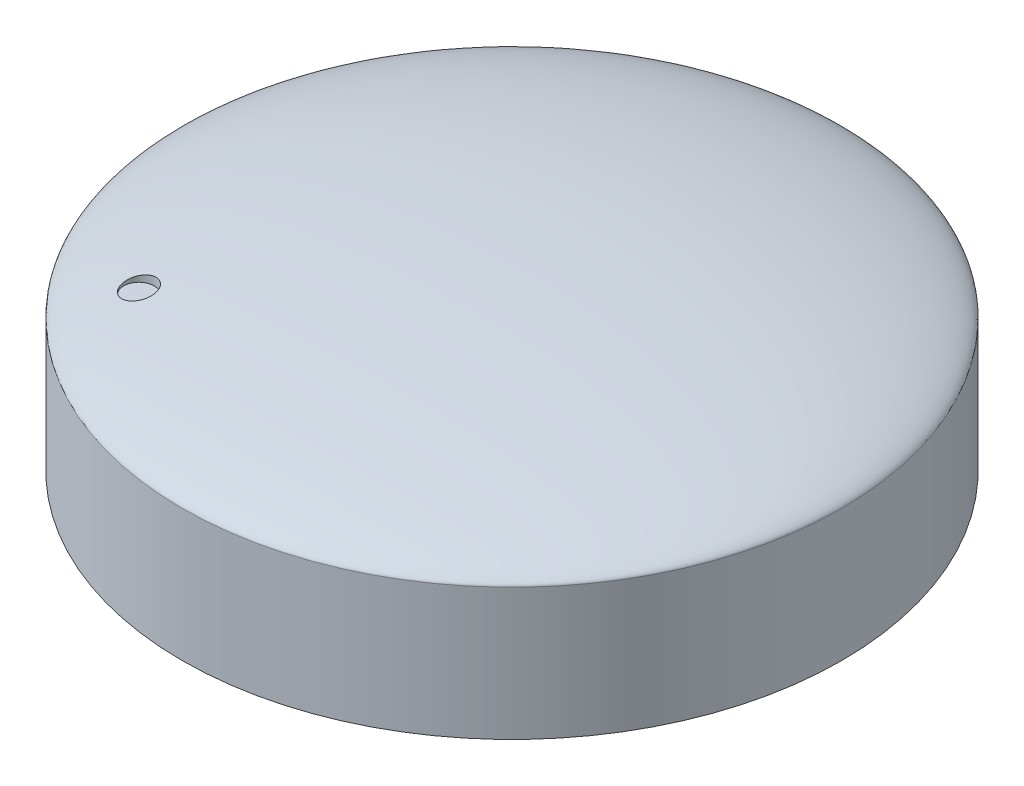
from build123d import *

# Parameters (mm, degrees)
ESQUISSE1_R             = 32.5
BOSS_EXTRU_1_DEPTH      = 18
ESQUISSE3_R             = 1.5
ENL_V_MAT_EXTRU_1_DEPTH = 3
ESQUISSE4_R             = 14.75
BOSS_EXTRU_3_DEPTH      = 12


with BuildPart() as part:
    # Esquisse1 → Boss.-Extru.1 (new body)
    with BuildSketch(Plane(origin=(0, 0, 0), x_dir=(1, 0, 0), z_dir=(0, 1, 0))):
        Circle(ESQUISSE1_R)
    extrude(amount=BOSS_EXTRU_1_DEPTH)

    # Esquisse2 → Enlèvement de matière-Révolution1 (revolve, cut)
    with BuildSketch(Plane.XY):
        with BuildLine():
            Line((-32.5, 13), (-32.5, 19))
            Line((-32.5, 19), (0, 19))
            Line((0, 19), (0, 18))
            add(Edge.make_bspline(
                [(-32.5, 13), (-32.5, 14.172258114), (-21.601405785, 18), (0, 18)],
                knots=[0, 0, 0, 0, 1, 1, 1, 1], degree=3))
        make_face()
    revolve(axis=Axis((0, 0, 0), (0, 1, 0)), mode=Mode.SUBTRACT)

    # Esquisse3 → Enlèv. mat.-Extru.1 (cut)
    with BuildSketch(Plane(origin=(0, 18, 0), x_dir=(1, 0, 0), z_dir=(0, 1, 0))):
        with Locations((-18.384776311, -18.384776311)):
            Circle(ESQUISSE3_R)
    extrude(amount=-ENL_V_MAT_EXTRU_1_DEPTH, mode=Mode.SUBTRACT)

    # Esquisse4 → Boss.-Extru.3 (add)
    with BuildSketch(Plane(origin=(0, 0, 0), x_dir=(1, 0, 0), z_dir=(0, 1, 0))):
        Circle(ESQUISSE4_R)
    extrude(amount=-BOSS_EXTRU_3_DEPTH)


solid = part.part
